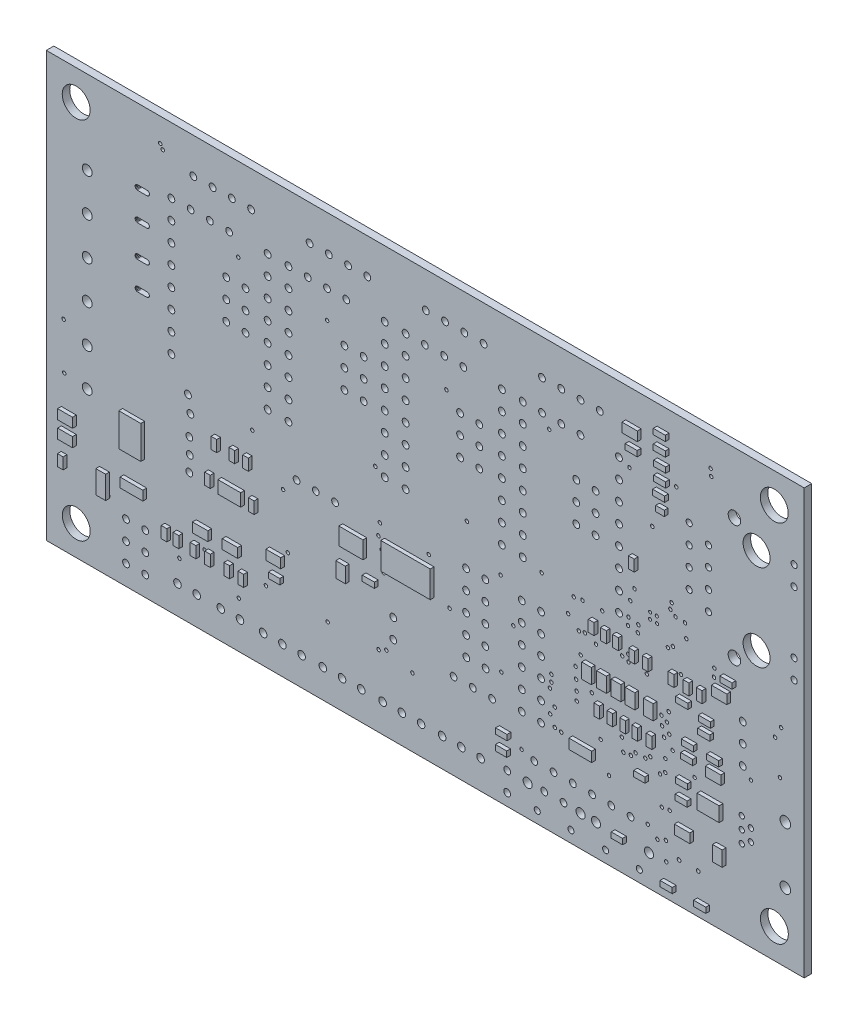
from build123d import *

# Parameters (mm, degrees)
SKETCH1_W           = 100
SKETCH1_H           = 56
SKETCH1_R           = 0.2286
SKETCH1_R_2         = 0.45
SKETCH1_R_3         = 0.2032
SKETCH1_R_4         = 0.4
SKETCH1_R_5         = 0.6
SKETCH1_R_6         = 1.778
SKETCH1_R_7         = 0.4064
SKETCH1_R_8         = 0.8255
SKETCH1_R_9         = 0.4445
SKETCH1_R_10        = 1.8415
SKETCH1_R_11        = 0.5
SKETCH1_R_12        = 0.65
SKETCH1_R_13        = 0.7
SKETCH1_R_14        = 0.35
SKETCH1_R_15        = 0.25
BOSS_EXTRUDE1_DEPTH = 0.991
SKETCH3_W           = 14.03
SKETCH3_H           = 14.03
BOSS_EXTRUDE2_DEPTH = 1.61
CHAMFER1_SIZE       = 0.61
CHAMFER2_SIZE       = 0.61
SKETCH4_W           = 1.304957509
SKETCH4_H           = 3.011808396
SKETCH4_W_2         = 0.747676452
SKETCH4_H_2         = 1.493492764
SKETCH4_W_3         = 1.967512926
SKETCH4_H_3         = 1.275000018
SKETCH4_H_4         = 1.275000015
SKETCH4_W_4         = 3.011798701
SKETCH4_H_5         = 1.246641716
SKETCH4_H_6         = 1.511746408
SKETCH4_W_5         = 0.747676453
SKETCH4_H_7         = 1.511746407
SKETCH4_W_6         = 0.765000025
SKETCH4_W_7         = 0.765000024
SKETCH4_H_8         = 1.493492763
SKETCH4_W_8         = 2.039999962
SKETCH4_H_9         = 1.246482293
SKETCH4_W_9         = 2.039999961
SKETCH4_W_10        = 1.967512925
SKETCH4_W_11        = 1.493492761
SKETCH4_H_10        = 0.74767645
SKETCH4_W_12        = 1.275000015
SKETCH4_H_11        = 2.015661876
SKETCH4_W_13        = 1.60649999
SKETCH4_H_12        = 0.726022008
SKETCH4_W_14        = 3.18
SKETCH4_H_13        = 2.28
SKETCH4_W_15        = 6.527994472
SKETCH4_H_14        = 3.518567085
SKETCH4_H_15        = 0.747676452
SKETCH4_W_16        = 1.511746405
SKETCH4_H_16        = 0.728187441
SKETCH4_W_17        = 1.587333678
SKETCH4_H_17        = 0.728187442
SKETCH4_W_18        = 1.587333679
SKETCH4_H_18        = 1.222102323
SKETCH4_H_19        = 1.222102324
SKETCH4_W_19        = 1.129246393
SKETCH4_H_20        = 0.726022005
SKETCH4_H_21        = 0.73035288
SKETCH4_W_20        = 1.275000018
SKETCH4_H_22        = 1.991323711
SKETCH4_W_21        = 2.91209749
SKETCH4_H_23        = 1.929775795
SKETCH4_W_22        = 1.275000016
SKETCH4_H_24        = 1.967512926
SKETCH4_H_25        = 1.967512925
SKETCH4_W_23        = 3.011808396
SKETCH4_H_26        = 1.304957507
SKETCH4_W_24        = 3.007851747
SKETCH4_H_27        = 1.656233035
SKETCH4_W_25        = 0.765000027
SKETCH4_H_28        = 1.568167369
SKETCH4_W_26        = 2.912100155
SKETCH4_H_29        = 4.346021334
BOSS_EXTRUDE3_DEPTH = 0.5


with BuildPart() as part:
    # Sketch1 → Boss-Extrude1 (new body)
    with BuildSketch(Plane.XY):
        with Locations((13.307133333, 19.688733333)):
            Rectangle(SKETCH1_W, SKETCH1_H)
        with Locations((16.517133333, 10.542066667)):
            Circle(SKETCH1_R, mode=Mode.SUBTRACT)
        with Locations((16.1038, 35.292066667)):
            Circle(SKETCH1_R, mode=Mode.SUBTRACT)
        with Locations((23.247133333, 17.708733333)):
            Circle(SKETCH1_R, mode=Mode.SUBTRACT)
        with Locations((28.654966667, 20.675)):
            Circle(SKETCH1_R, mode=Mode.SUBTRACT)
        with Locations((33.2873, 8.324)):
            Circle(SKETCH1_R, mode=Mode.SUBTRACT)
        with Locations((29.7584, 8.038833333)):
            Circle(SKETCH1_R, mode=Mode.SUBTRACT)
        with Locations((7.324866667, 15.717566667)):
            Circle(SKETCH1_R, mode=Mode.SUBTRACT)
        with Locations((0.357133333, 35.348733333)):
            Circle(SKETCH1_R, mode=Mode.SUBTRACT)
        with Locations((18.7985, 21.621333333)):
            Circle(SKETCH1_R, mode=Mode.SUBTRACT)
        with Locations((29.953666667, 9.716366667)):
            Circle(SKETCH1_R, mode=Mode.SUBTRACT)
        with Locations((29.957133333, 8.818733333)):
            Circle(SKETCH1_R, mode=Mode.SUBTRACT)
        with Locations((13.775033333, 15.313666667)):
            Circle(SKETCH1_R, mode=Mode.SUBTRACT)
        with Locations((-11.3662, 36.7154)):
            Circle(SKETCH1_R, mode=Mode.SUBTRACT)
        with Locations((-9.514866667, 17.868733333)):
            Circle(SKETCH1_R, mode=Mode.SUBTRACT)
        with Locations((31.240733333, 3.7565)):
            Circle(SKETCH1_R, mode=Mode.SUBTRACT)
        with Locations((23.347133333, 6.668733333)):
            Circle(SKETCH1_R, mode=Mode.SUBTRACT)
        with Locations((-4.822866667, 6.2254)):
            Circle(SKETCH1_R, mode=Mode.SUBTRACT)
        with Locations((-5.455866667, 13.126533333)):
            Circle(SKETCH1_R, mode=Mode.SUBTRACT)
        with Locations((44.280266667, 5.492133333)):
            Circle(SKETCH1_R, mode=Mode.SUBTRACT)
        with Locations((44.978, 6.005366667)):
            Circle(SKETCH1_R, mode=Mode.SUBTRACT)
        with Locations((44.4754, 12.311333333)):
            Circle(SKETCH1_R, mode=Mode.SUBTRACT)
        with Locations((43.267133333, 33.278733333)):
            Circle(SKETCH1_R, mode=Mode.SUBTRACT)
        with Locations((42.6598, -1.0665)):
            Circle(SKETCH1_R, mode=Mode.SUBTRACT)
        with Locations((34.367133333, 16.658733333)):
            Circle(SKETCH1_R, mode=Mode.SUBTRACT)
        with Locations((60.109233333, 12.993033333)):
            Circle(SKETCH1_R, mode=Mode.SUBTRACT)
        with Locations((34.054133333, 20.227433333)):
            Circle(SKETCH1_R, mode=Mode.SUBTRACT)
        with Locations((32.895666667, 20.0402)):
            Circle(SKETCH1_R, mode=Mode.SUBTRACT)
        with Locations((59.464766667, 17.276366667)):
            Circle(SKETCH1_R, mode=Mode.SUBTRACT)
        with Locations((35.836333333, 16.1019)):
            Circle(SKETCH1_R, mode=Mode.SUBTRACT)
        with Locations((45.058033333, -1.707333333)):
            Circle(SKETCH1_R, mode=Mode.SUBTRACT)
        with Locations((45.196033333, 11.876533333)):
            Circle(SKETCH1_R, mode=Mode.SUBTRACT)
        with Locations((45.497133333, 10.638733333)):
            Circle(SKETCH1_R, mode=Mode.SUBTRACT)
        with Locations((47.577133333, 24.406633333)):
            Circle(SKETCH1_R, mode=Mode.SUBTRACT)
        with Locations((45.942433333, 9.0166)):
            Circle(SKETCH1_R, mode=Mode.SUBTRACT)
        with Locations((7.1314, 14.127733333)):
            Circle(SKETCH1_R, mode=Mode.SUBTRACT)
        with Locations((8.1788, 1.5814)):
            Circle(SKETCH1_R, mode=Mode.SUBTRACT)
        with Locations((7.150466667, 1.132433333)):
            Circle(SKETCH1_R, mode=Mode.SUBTRACT)
        with Locations((7.560233333, 12.723533333)):
            Circle(SKETCH1_R, mode=Mode.SUBTRACT)
        with Locations((33.570733333, 16.4904)):
            Circle(SKETCH1_R, mode=Mode.SUBTRACT)
        with Locations((30.405466667, 3.868966667)):
            Circle(SKETCH1_R, mode=Mode.SUBTRACT)
        with Locations((33.817133333, 13.858733333)):
            Circle(SKETCH1_R, mode=Mode.SUBTRACT)
        with Locations((45.554133333, 1.960466667)):
            Circle(SKETCH1_R, mode=Mode.SUBTRACT)
        with Locations((44.522833333, 1.823566667)):
            Circle(SKETCH1_R, mode=Mode.SUBTRACT)
        with Locations((29.78, 5.116033333)):
            Circle(SKETCH1_R, mode=Mode.SUBTRACT)
        with Locations((35.280466667, 10.2754)):
            Circle(SKETCH1_R, mode=Mode.SUBTRACT)
        with Locations((33.137266667, 12.216166667)):
            Circle(SKETCH1_R, mode=Mode.SUBTRACT)
        with Locations((24.935866667, 12.76)):
            Circle(SKETCH1_R, mode=Mode.SUBTRACT)
        with Locations((44.9896, 7.609033333)):
            Circle(SKETCH1_R, mode=Mode.SUBTRACT)
        with Locations((36.447133333, 5.518733333)):
            Circle(SKETCH1_R, mode=Mode.SUBTRACT)
        with Locations((48.840466667, 7.3754)):
            Circle(SKETCH1_R, mode=Mode.SUBTRACT)
        with Locations((39.448433333, 5.549133333)):
            Circle(SKETCH1_R, mode=Mode.SUBTRACT)
        with Locations((40.437133333, 5.692066667)):
            Circle(SKETCH1_R, mode=Mode.SUBTRACT)
        with Locations((33.274433333, 9.458733333)):
            Circle(SKETCH1_R, mode=Mode.SUBTRACT)
        with Locations((33.2072, 10.780633333)):
            Circle(SKETCH1_R, mode=Mode.SUBTRACT)
        with Locations((-19.129533333, -1.5746)):
            Circle(SKETCH1_R, mode=Mode.SUBTRACT)
        with Locations((45.4266, 13.179366667)):
            Circle(SKETCH1_R, mode=Mode.SUBTRACT)
        with Locations((11.617133333, 0.7045)):
            Circle(SKETCH1_R, mode=Mode.SUBTRACT)
        with Locations((41.427133333, 21.1092)):
            Circle(SKETCH1_R, mode=Mode.SUBTRACT)
        with Locations((47.747133333, 22.678733333)):
            Circle(SKETCH1_R, mode=Mode.SUBTRACT)
        with Locations((40.917133333, 24.978733333)):
            Circle(SKETCH1_R, mode=Mode.SUBTRACT)
        with Locations((41.361033333, 20.165566667)):
            Circle(SKETCH1_R, mode=Mode.SUBTRACT)
        with Locations((46.427133333, 39.368733333)):
            Circle(SKETCH1_R, mode=Mode.SUBTRACT)
        with Locations((40.2556, 38.4838)):
            Circle(SKETCH1_R, mode=Mode.SUBTRACT)
        with Locations((40.357133333, 23.338733333)):
            Circle(SKETCH1_R, mode=Mode.SUBTRACT)
        with Locations((41.054133333, 6.2989)):
            Circle(SKETCH1_R, mode=Mode.SUBTRACT)
        with Locations((39.253133333, 7.182733333)):
            Circle(SKETCH1_R, mode=Mode.SUBTRACT)
        with Locations((42.338833333, 6.328733333)):
            Circle(SKETCH1_R, mode=Mode.SUBTRACT)
        with Locations((42.9945, 6.828033333)):
            Circle(SKETCH1_R, mode=Mode.SUBTRACT)
        with Locations((30.386433333, 6.186533333)):
            Circle(SKETCH1_R, mode=Mode.SUBTRACT)
        with Locations((-34.406866667, 18.111466667)):
            Circle(SKETCH1_R, mode=Mode.SUBTRACT)
        with Locations((-28.5043, 0.940866667)):
            Circle(SKETCH1_R, mode=Mode.SUBTRACT)
        with Locations((26.011566667, -0.8344)):
            Circle(SKETCH1_R, mode=Mode.SUBTRACT)
        with Locations((7.8107, 10.236633333)):
            Circle(SKETCH1_R, mode=Mode.SUBTRACT)
        with Locations((29.667133333, 37.558733333)):
            Circle(SKETCH1_R, mode=Mode.SUBTRACT)
        with Locations((45.657133333, 24.988733333)):
            Circle(SKETCH1_R, mode=Mode.SUBTRACT)
        with Locations((46.327133333, 24.488733333)):
            Circle(SKETCH1_R, mode=Mode.SUBTRACT)
        with Locations((45.807133333, 25.828733333)):
            Circle(SKETCH1_R, mode=Mode.SUBTRACT)
        with Locations((40.091166667, 17.0729)):
            Circle(SKETCH1_R, mode=Mode.SUBTRACT)
        with Locations((40.123066667, 16.205066667)):
            Circle(SKETCH1_R, mode=Mode.SUBTRACT)
        with Locations((40.120466667, 21.342066667)):
            Circle(SKETCH1_R, mode=Mode.SUBTRACT)
        with Locations((47.047133333, 18.238733333)):
            Circle(SKETCH1_R, mode=Mode.SUBTRACT)
        with Locations((51.4538, 21.1754)):
            Circle(SKETCH1_R, mode=Mode.SUBTRACT)
        with Locations((40.060466667, 20.342066667)):
            Circle(SKETCH1_R, mode=Mode.SUBTRACT)
        with Locations((36.657133333, 20.318733333)):
            Circle(SKETCH1_R, mode=Mode.SUBTRACT)
        with Locations((45.325533333, 20.4579)):
            Circle(SKETCH1_R, mode=Mode.SUBTRACT)
        with Locations((39.297133333, 16.488733333)):
            Circle(SKETCH1_R, mode=Mode.SUBTRACT)
        with Locations((45.987133333, 20.918733333)):
            Circle(SKETCH1_R, mode=Mode.SUBTRACT)
        with Locations((42.541533333, 16.037033333)):
            Circle(SKETCH1_R, mode=Mode.SUBTRACT)
        with Locations((-11.2929, -2.2113)):
            Circle(SKETCH1_R, mode=Mode.SUBTRACT)
        with Locations((32.157133333, 17.748733333)):
            Circle(SKETCH1_R, mode=Mode.SUBTRACT)
        with Locations((-15.7962, 1.048733333)):
            Circle(SKETCH1_R, mode=Mode.SUBTRACT)
        with Locations((45.107133333, -4.131266667)):
            Circle(SKETCH1_R, mode=Mode.SUBTRACT)
        with Locations((44.814766667, 9.958733333)):
            Circle(SKETCH1_R, mode=Mode.SUBTRACT)
        with Locations((0.4297, 0.934466667)):
            Circle(SKETCH1_R, mode=Mode.SUBTRACT)
        with Locations((43.940133333, -2.1493)):
            Circle(SKETCH1_R, mode=Mode.SUBTRACT)
        with Locations((51.4038, 20.1054)):
            Circle(SKETCH1_R, mode=Mode.SUBTRACT)
        with Locations((56.2838, 10.788733333)):
            Circle(SKETCH1_R, mode=Mode.SUBTRACT)
        with Locations((60.252366667, 18.778733333)):
            Circle(SKETCH1_R, mode=Mode.SUBTRACT)
        with Locations((44.5511, 11.129766667)):
            Circle(SKETCH1_R, mode=Mode.SUBTRACT)
        with Locations((-7.712866667, 1.008733333)):
            Circle(SKETCH1_R, mode=Mode.SUBTRACT)
        with Locations((6.717133333, 21.8554)):
            Circle(SKETCH1_R, mode=Mode.SUBTRACT)
        with Locations((37.554133333, 1.958466667)):
            Circle(SKETCH1_R, mode=Mode.SUBTRACT)
        with Locations((51.046, 42.863433333)):
            Circle(SKETCH1_R, mode=Mode.SUBTRACT)
        with Locations((50.954666667, 43.742866667)):
            Circle(SKETCH1_R, mode=Mode.SUBTRACT)
        with Locations((-21.327033333, 44.012166667)):
            Circle(SKETCH1_R, mode=Mode.SUBTRACT)
        with Locations((-21.664366667, 44.555966667)):
            Circle(SKETCH1_R, mode=Mode.SUBTRACT)
        with Locations((-34.329733333, 12.002933333)):
            Circle(SKETCH1_R, mode=Mode.SUBTRACT)
        with Locations((-9.669533333, 43.021366667)):
            Circle(SKETCH1_R_2, mode=Mode.SUBTRACT)
        with Locations((-12.209533333, 43.021366667)):
            Circle(SKETCH1_R_2, mode=Mode.SUBTRACT)
        with Locations((-14.749533333, 43.016733333)):
            Circle(SKETCH1_R_2, mode=Mode.SUBTRACT)
        with Locations((-17.289533333, 43.012066667)):
            Circle(SKETCH1_R_2, mode=Mode.SUBTRACT)
        with Locations((5.667133333, 43.031366667)):
            Circle(SKETCH1_R_2, mode=Mode.SUBTRACT)
        with Locations((3.127133333, 43.031366667)):
            Circle(SKETCH1_R_2, mode=Mode.SUBTRACT)
        with Locations((0.587133333, 43.026733333)):
            Circle(SKETCH1_R_2, mode=Mode.SUBTRACT)
        with Locations((-1.952866667, 43.022066667)):
            Circle(SKETCH1_R_2, mode=Mode.SUBTRACT)
        with Locations((21.0038, 43.021366667)):
            Circle(SKETCH1_R_2, mode=Mode.SUBTRACT)
        with Locations((18.4638, 43.021366667)):
            Circle(SKETCH1_R_2, mode=Mode.SUBTRACT)
        with Locations((15.9238, 43.016733333)):
            Circle(SKETCH1_R_2, mode=Mode.SUBTRACT)
        with Locations((13.3838, 43.012066667)):
            Circle(SKETCH1_R_2, mode=Mode.SUBTRACT)
        with Locations((36.3338, 43.001366667)):
            Circle(SKETCH1_R_2, mode=Mode.SUBTRACT)
        with Locations((33.7938, 43.001366667)):
            Circle(SKETCH1_R_2, mode=Mode.SUBTRACT)
        with Locations((31.2538, 42.996733333)):
            Circle(SKETCH1_R_2, mode=Mode.SUBTRACT)
        with Locations((28.7138, 42.992066667)):
            Circle(SKETCH1_R_2, mode=Mode.SUBTRACT)
        with Locations((42.977133333, 22.508733333)):
            Circle(SKETCH1_R_3, mode=Mode.SUBTRACT)
        with Locations((43.888866667, 22.474)):
            Circle(SKETCH1_R_3, mode=Mode.SUBTRACT)
        with Locations((43.854133333, 23.324933333)):
            Circle(SKETCH1_R_3, mode=Mode.SUBTRACT)
        with Locations((42.985833333, 23.324933333)):
            Circle(SKETCH1_R_3, mode=Mode.SUBTRACT)
        with Locations((32.531166667, -6.787266667)):
            Circle(SKETCH1_R_4, mode=Mode.SUBTRACT)
        with Locations((28.086166667, -6.787266667)):
            Circle(SKETCH1_R_4, mode=Mode.SUBTRACT)
        with Locations((33.801166667, -4.247266667)):
            Circle(SKETCH1_R_5, mode=Mode.SUBTRACT)
        with Locations((26.816166667, -4.247266667)):
            Circle(SKETCH1_R_5, mode=Mode.SUBTRACT)
        with Locations((57.024133333, 37.387733333)):
            Circle(SKETCH1_R_6, mode=Mode.SUBTRACT)
        with Locations((57.024133333, 25.957733333)):
            Circle(SKETCH1_R_6, mode=Mode.SUBTRACT)
        with Locations((61.977133333, 35.736733333)):
            Circle(SKETCH1_R_7, mode=Mode.SUBTRACT)
        with Locations((61.977133333, 38.276733333)):
            Circle(SKETCH1_R_7, mode=Mode.SUBTRACT)
        with Locations((48.134133333, 28.497733333)):
            Circle(SKETCH1_R_7, mode=Mode.SUBTRACT)
        with Locations((50.674133333, 27.227733333)):
            Circle(SKETCH1_R_7, mode=Mode.SUBTRACT)
        with Locations((54.103133333, 23.671733333)):
            Circle(SKETCH1_R_8, mode=Mode.SUBTRACT)
        with Locations((54.103133333, 39.673733333)):
            Circle(SKETCH1_R_8, mode=Mode.SUBTRACT)
        with Locations((48.134133333, 33.577733333)):
            Circle(SKETCH1_R_7, mode=Mode.SUBTRACT)
        with Locations((50.674133333, 29.767733333)):
            Circle(SKETCH1_R_7, mode=Mode.SUBTRACT)
        with Locations((50.674133333, 32.307733333)):
            Circle(SKETCH1_R_7, mode=Mode.SUBTRACT)
        with Locations((48.134133333, 31.037733333)):
            Circle(SKETCH1_R_7, mode=Mode.SUBTRACT)
        with Locations((50.674133333, 34.847733333)):
            Circle(SKETCH1_R_7, mode=Mode.SUBTRACT)
        with Locations((48.134133333, 36.117733333)):
            Circle(SKETCH1_R_7, mode=Mode.SUBTRACT)
        with Locations((61.977133333, 27.608733333)):
            Circle(SKETCH1_R_7, mode=Mode.SUBTRACT)
        with Locations((61.977133333, 25.068733333)):
            Circle(SKETCH1_R_7, mode=Mode.SUBTRACT)
        with Locations((9.088633333, 3.244966667)):
            Circle(SKETCH1_R_9, mode=Mode.SUBTRACT)
        with Locations((9.088633333, 5.784966667)):
            Circle(SKETCH1_R_9, mode=Mode.SUBTRACT)
        with Locations((21.269933333, 6.039733333)):
            Circle(SKETCH1_R_9, mode=Mode.SUBTRACT)
        with Locations((18.729933333, 6.039733333)):
            Circle(SKETCH1_R_9, mode=Mode.SUBTRACT)
        with Locations((41.5524, -6.778766667)):
            Circle(SKETCH1_R_4, mode=Mode.SUBTRACT)
        with Locations((37.1074, -6.778766667)):
            Circle(SKETCH1_R_4, mode=Mode.SUBTRACT)
        with Locations((42.8224, -4.238766667)):
            Circle(SKETCH1_R_5, mode=Mode.SUBTRACT)
        with Locations((35.8374, -4.238766667)):
            Circle(SKETCH1_R_5, mode=Mode.SUBTRACT)
        with Locations((59.3696, -4.380766667)):
            Circle(SKETCH1_R_10, mode=Mode.SUBTRACT)
        with Locations((59.360433333, 43.742233333)):
            Circle(SKETCH1_R_10, mode=Mode.SUBTRACT)
        with Locations((-32.7488, 43.734533333)):
            Circle(SKETCH1_R_10, mode=Mode.SUBTRACT)
        with Locations((-32.740366667, -4.374766667)):
            Circle(SKETCH1_R_10, mode=Mode.SUBTRACT)
        with Locations((-17.819533333, 12.9654)):
            Circle(SKETCH1_R_2, mode=Mode.SUBTRACT)
        with Locations((-17.818433333, 8.893166667)):
            Circle(SKETCH1_R_2, mode=Mode.SUBTRACT)
        with Locations((-17.762866667, 10.928733333)):
            Circle(SKETCH1_R_2, mode=Mode.SUBTRACT)
        with Locations((-17.682066667, 15.652966667)):
            Circle(SKETCH1_R_2, mode=Mode.SUBTRACT)
        with Locations((-18.002866667, 17.718733333)):
            Circle(SKETCH1_R_2, mode=Mode.SUBTRACT)
        with Locations((33.7912, 38.9854)):
            Circle(SKETCH1_R_9, mode=Mode.SUBTRACT)
        with Locations((31.2512, 38.9854)):
            Circle(SKETCH1_R_9, mode=Mode.SUBTRACT)
        with Locations((28.7112, 38.9854)):
            Circle(SKETCH1_R_9, mode=Mode.SUBTRACT)
        with Locations((26.1712, 21.2054)):
            Circle(SKETCH1_R_2, mode=Mode.SUBTRACT)
        with Locations((26.1712, 36.4454)):
            Circle(SKETCH1_R_2, mode=Mode.SUBTRACT)
        with Locations((38.8712, 36.4454)):
            Circle(SKETCH1_R_2, mode=Mode.SUBTRACT)
        with Locations((38.8712, 33.9054)):
            Circle(SKETCH1_R_2, mode=Mode.SUBTRACT)
        with Locations((38.8712, 31.3654)):
            Circle(SKETCH1_R_2, mode=Mode.SUBTRACT)
        with Locations((38.8712, 28.8254)):
            Circle(SKETCH1_R_2, mode=Mode.SUBTRACT)
        with Locations((38.8712, 26.2854)):
            Circle(SKETCH1_R_2, mode=Mode.SUBTRACT)
        with Locations((38.8712, 23.7454)):
            Circle(SKETCH1_R_2, mode=Mode.SUBTRACT)
        with Locations((26.1712, 23.7454)):
            Circle(SKETCH1_R_2, mode=Mode.SUBTRACT)
        with Locations((26.1712, 38.9854)):
            Circle(SKETCH1_R_2, mode=Mode.SUBTRACT)
        with Locations((38.8712, 21.2054)):
            Circle(SKETCH1_R_2, mode=Mode.SUBTRACT)
        with Locations((38.8712, 38.9854)):
            Circle(SKETCH1_R_2, mode=Mode.SUBTRACT)
        with Locations((26.1712, 26.2854)):
            Circle(SKETCH1_R_2, mode=Mode.SUBTRACT)
        with Locations((26.1712, 28.8254)):
            Circle(SKETCH1_R_2, mode=Mode.SUBTRACT)
        with Locations((26.1712, 33.9054)):
            Circle(SKETCH1_R_2, mode=Mode.SUBTRACT)
        with Locations((26.1712, 31.3654)):
            Circle(SKETCH1_R_2, mode=Mode.SUBTRACT)
        with Locations((18.337133333, 39.0254)):
            Circle(SKETCH1_R_9, mode=Mode.SUBTRACT)
        with Locations((15.797133333, 39.0254)):
            Circle(SKETCH1_R_9, mode=Mode.SUBTRACT)
        with Locations((13.257133333, 39.0254)):
            Circle(SKETCH1_R_9, mode=Mode.SUBTRACT)
        with Locations((10.717133333, 21.2454)):
            Circle(SKETCH1_R_2, mode=Mode.SUBTRACT)
        with Locations((10.717133333, 36.4854)):
            Circle(SKETCH1_R_2, mode=Mode.SUBTRACT)
        with Locations((23.417133333, 36.4854)):
            Circle(SKETCH1_R_2, mode=Mode.SUBTRACT)
        with Locations((23.417133333, 33.9454)):
            Circle(SKETCH1_R_2, mode=Mode.SUBTRACT)
        with Locations((23.417133333, 31.4054)):
            Circle(SKETCH1_R_2, mode=Mode.SUBTRACT)
        with Locations((23.417133333, 28.8654)):
            Circle(SKETCH1_R_2, mode=Mode.SUBTRACT)
        with Locations((23.417133333, 26.3254)):
            Circle(SKETCH1_R_2, mode=Mode.SUBTRACT)
        with Locations((23.417133333, 23.7854)):
            Circle(SKETCH1_R_2, mode=Mode.SUBTRACT)
        with Locations((10.717133333, 23.7854)):
            Circle(SKETCH1_R_2, mode=Mode.SUBTRACT)
        with Locations((10.717133333, 39.0254)):
            Circle(SKETCH1_R_2, mode=Mode.SUBTRACT)
        with Locations((23.417133333, 21.2454)):
            Circle(SKETCH1_R_2, mode=Mode.SUBTRACT)
        with Locations((23.417133333, 39.0254)):
            Circle(SKETCH1_R_2, mode=Mode.SUBTRACT)
        with Locations((10.717133333, 26.3254)):
            Circle(SKETCH1_R_2, mode=Mode.SUBTRACT)
        with Locations((10.717133333, 28.8654)):
            Circle(SKETCH1_R_2, mode=Mode.SUBTRACT)
        with Locations((10.717133333, 33.9454)):
            Circle(SKETCH1_R_2, mode=Mode.SUBTRACT)
        with Locations((10.717133333, 31.4054)):
            Circle(SKETCH1_R_2, mode=Mode.SUBTRACT)
        with Locations((2.8838, 39.0154)):
            Circle(SKETCH1_R_9, mode=Mode.SUBTRACT)
        with Locations((0.3438, 39.0154)):
            Circle(SKETCH1_R_9, mode=Mode.SUBTRACT)
        with Locations((-2.1962, 39.0154)):
            Circle(SKETCH1_R_9, mode=Mode.SUBTRACT)
        with Locations((-4.7362, 21.2354)):
            Circle(SKETCH1_R_2, mode=Mode.SUBTRACT)
        with Locations((-4.7362, 36.4754)):
            Circle(SKETCH1_R_2, mode=Mode.SUBTRACT)
        with Locations((7.9638, 36.4754)):
            Circle(SKETCH1_R_2, mode=Mode.SUBTRACT)
        with Locations((7.9638, 33.9354)):
            Circle(SKETCH1_R_2, mode=Mode.SUBTRACT)
        with Locations((7.9638, 31.3954)):
            Circle(SKETCH1_R_2, mode=Mode.SUBTRACT)
        with Locations((7.9638, 28.8554)):
            Circle(SKETCH1_R_2, mode=Mode.SUBTRACT)
        with Locations((7.9638, 26.3154)):
            Circle(SKETCH1_R_2, mode=Mode.SUBTRACT)
        with Locations((7.9638, 23.7754)):
            Circle(SKETCH1_R_2, mode=Mode.SUBTRACT)
        with Locations((-4.7362, 23.7754)):
            Circle(SKETCH1_R_2, mode=Mode.SUBTRACT)
        with Locations((-4.7362, 39.0154)):
            Circle(SKETCH1_R_2, mode=Mode.SUBTRACT)
        with Locations((7.9638, 21.2354)):
            Circle(SKETCH1_R_2, mode=Mode.SUBTRACT)
        with Locations((7.9638, 39.0154)):
            Circle(SKETCH1_R_2, mode=Mode.SUBTRACT)
        with Locations((-4.7362, 26.3154)):
            Circle(SKETCH1_R_2, mode=Mode.SUBTRACT)
        with Locations((-4.7362, 28.8554)):
            Circle(SKETCH1_R_2, mode=Mode.SUBTRACT)
        with Locations((-4.7362, 33.9354)):
            Circle(SKETCH1_R_2, mode=Mode.SUBTRACT)
        with Locations((-4.7362, 31.3954)):
            Circle(SKETCH1_R_2, mode=Mode.SUBTRACT)
        with Locations((-12.569533333, 39.0254)):
            Circle(SKETCH1_R_9, mode=Mode.SUBTRACT)
        with Locations((-15.109533333, 39.0254)):
            Circle(SKETCH1_R_9, mode=Mode.SUBTRACT)
        with Locations((-17.649533333, 39.0254)):
            Circle(SKETCH1_R_9, mode=Mode.SUBTRACT)
        with Locations((-20.189533333, 21.2454)):
            Circle(SKETCH1_R_2, mode=Mode.SUBTRACT)
        with Locations((-20.189533333, 36.4854)):
            Circle(SKETCH1_R_2, mode=Mode.SUBTRACT)
        with Locations((-7.489533333, 36.4854)):
            Circle(SKETCH1_R_2, mode=Mode.SUBTRACT)
        with Locations((-7.489533333, 33.9454)):
            Circle(SKETCH1_R_2, mode=Mode.SUBTRACT)
        with Locations((-7.489533333, 31.4054)):
            Circle(SKETCH1_R_2, mode=Mode.SUBTRACT)
        with Locations((-7.489533333, 28.8654)):
            Circle(SKETCH1_R_2, mode=Mode.SUBTRACT)
        with Locations((-7.489533333, 26.3254)):
            Circle(SKETCH1_R_2, mode=Mode.SUBTRACT)
        with Locations((-7.489533333, 23.7854)):
            Circle(SKETCH1_R_2, mode=Mode.SUBTRACT)
        with Locations((-20.189533333, 23.7854)):
            Circle(SKETCH1_R_2, mode=Mode.SUBTRACT)
        with Locations((-20.189533333, 39.0254)):
            Circle(SKETCH1_R_2, mode=Mode.SUBTRACT)
        with Locations((-7.489533333, 21.2454)):
            Circle(SKETCH1_R_2, mode=Mode.SUBTRACT)
        with Locations((-7.489533333, 39.0254)):
            Circle(SKETCH1_R_2, mode=Mode.SUBTRACT)
        with Locations((-20.189533333, 26.3254)):
            Circle(SKETCH1_R_2, mode=Mode.SUBTRACT)
        with Locations((-20.189533333, 28.8654)):
            Circle(SKETCH1_R_2, mode=Mode.SUBTRACT)
        with Locations((-20.189533333, 33.9454)):
            Circle(SKETCH1_R_2, mode=Mode.SUBTRACT)
        with Locations((-20.189533333, 31.4054)):
            Circle(SKETCH1_R_2, mode=Mode.SUBTRACT)
        with Locations((55.197133333, 16.9454)):
            Circle(SKETCH1_R_9, mode=Mode.SUBTRACT)
        with Locations((55.197133333, 14.4054)):
            Circle(SKETCH1_R_9, mode=Mode.SUBTRACT)
        with Locations((55.197133333, 11.8654)):
            Circle(SKETCH1_R_9, mode=Mode.SUBTRACT)
        with Locations((-13.6768, -4.579166667)):
            Circle(SKETCH1_R_11, mode=Mode.SUBTRACT)
        with Locations((-11.1368, -4.5745)):
            Circle(SKETCH1_R_11, mode=Mode.SUBTRACT)
        with Locations((-19.384666667, -4.579166667)):
            Circle(SKETCH1_R_11, mode=Mode.SUBTRACT)
        with Locations((-16.844666667, -4.5745)):
            Circle(SKETCH1_R_11, mode=Mode.SUBTRACT)
        with Locations((-3.672866667, 15.0986)):
            Circle(SKETCH1_R_9, mode=Mode.SUBTRACT)
        with Locations((-1.132866667, 15.0986)):
            Circle(SKETCH1_R_9, mode=Mode.SUBTRACT)
        with Locations((1.407133333, 15.0986)):
            Circle(SKETCH1_R_9, mode=Mode.SUBTRACT)
        with Locations((22.125833333, 3.001733333)):
            Circle(SKETCH1_R_9, mode=Mode.SUBTRACT)
        with Locations((19.585833333, 3.001733333)):
            Circle(SKETCH1_R_9, mode=Mode.SUBTRACT)
        with Locations((17.045833333, 3.001733333)):
            Circle(SKETCH1_R_9, mode=Mode.SUBTRACT)
        with Locations((15.531666667, -4.549433333)):
            Circle(SKETCH1_R_11, mode=Mode.SUBTRACT)
        with Locations((18.071666667, -4.5448)):
            Circle(SKETCH1_R_11, mode=Mode.SUBTRACT)
        with Locations((20.6117, -4.540133333)):
            Circle(SKETCH1_R_11, mode=Mode.SUBTRACT)
        with Locations((7.678066667, -4.549433333)):
            Circle(SKETCH1_R_11, mode=Mode.SUBTRACT)
        with Locations((10.218066667, -4.5448)):
            Circle(SKETCH1_R_11, mode=Mode.SUBTRACT)
        with Locations((12.7581, -4.540133333)):
            Circle(SKETCH1_R_11, mode=Mode.SUBTRACT)
        with Locations((-0.2119, -4.549433333)):
            Circle(SKETCH1_R_11, mode=Mode.SUBTRACT)
        with Locations((2.3281, -4.5448)):
            Circle(SKETCH1_R_11, mode=Mode.SUBTRACT)
        with Locations((4.868133333, -4.540133333)):
            Circle(SKETCH1_R_11, mode=Mode.SUBTRACT)
        with Locations((-8.0837, -4.585833333)):
            Circle(SKETCH1_R_11, mode=Mode.SUBTRACT)
        with Locations((-5.5437, -4.5812)):
            Circle(SKETCH1_R_11, mode=Mode.SUBTRACT)
        with Locations((-3.003666667, -4.576533333)):
            Circle(SKETCH1_R_11, mode=Mode.SUBTRACT)
        with Locations((-12.9462, 28.562066667)):
            Circle(SKETCH1_R_9, mode=Mode.SUBTRACT)
        with Locations((-12.9462, 31.102066667)):
            Circle(SKETCH1_R_9, mode=Mode.SUBTRACT)
        with Locations((-12.9462, 33.642066667)):
            Circle(SKETCH1_R_9, mode=Mode.SUBTRACT)
        with Locations((-10.4062, 28.562066667)):
            Circle(SKETCH1_R_9, mode=Mode.SUBTRACT)
        with Locations((-10.4062, 31.102066667)):
            Circle(SKETCH1_R_9, mode=Mode.SUBTRACT)
        with Locations((-10.4062, 33.642066667)):
            Circle(SKETCH1_R_9, mode=Mode.SUBTRACT)
        with Locations((2.640466667, 28.5454)):
            Circle(SKETCH1_R_9, mode=Mode.SUBTRACT)
        with Locations((2.640466667, 31.0854)):
            Circle(SKETCH1_R_9, mode=Mode.SUBTRACT)
        with Locations((2.640466667, 33.6254)):
            Circle(SKETCH1_R_9, mode=Mode.SUBTRACT)
        with Locations((5.180466667, 28.5454)):
            Circle(SKETCH1_R_9, mode=Mode.SUBTRACT)
        with Locations((5.180466667, 31.0854)):
            Circle(SKETCH1_R_9, mode=Mode.SUBTRACT)
        with Locations((5.180466667, 33.6254)):
            Circle(SKETCH1_R_9, mode=Mode.SUBTRACT)
        with Locations((17.899733333, 28.467933333)):
            Circle(SKETCH1_R_9, mode=Mode.SUBTRACT)
        with Locations((17.899733333, 31.007933333)):
            Circle(SKETCH1_R_9, mode=Mode.SUBTRACT)
        with Locations((17.899733333, 33.547933333)):
            Circle(SKETCH1_R_9, mode=Mode.SUBTRACT)
        with Locations((20.439733333, 28.467933333)):
            Circle(SKETCH1_R_9, mode=Mode.SUBTRACT)
        with Locations((20.439733333, 31.007933333)):
            Circle(SKETCH1_R_9, mode=Mode.SUBTRACT)
        with Locations((20.439733333, 33.547933333)):
            Circle(SKETCH1_R_9, mode=Mode.SUBTRACT)
        with Locations((33.238933333, 28.508733333)):
            Circle(SKETCH1_R_9, mode=Mode.SUBTRACT)
        with Locations((33.238933333, 31.048733333)):
            Circle(SKETCH1_R_9, mode=Mode.SUBTRACT)
        with Locations((33.238933333, 33.588733333)):
            Circle(SKETCH1_R_9, mode=Mode.SUBTRACT)
        with Locations((35.778933333, 28.508733333)):
            Circle(SKETCH1_R_9, mode=Mode.SUBTRACT)
        with Locations((35.778933333, 31.048733333)):
            Circle(SKETCH1_R_9, mode=Mode.SUBTRACT)
        with Locations((35.778933333, 33.588733333)):
            Circle(SKETCH1_R_9, mode=Mode.SUBTRACT)
        with Locations((24.1205, -6.733933333)):
            Circle(SKETCH1_R_9, mode=Mode.SUBTRACT)
        with Locations((24.1205, -4.193933333)):
            Circle(SKETCH1_R_9, mode=Mode.SUBTRACT)
        with Locations((27.696133333, -1.326266667)):
            Circle(SKETCH1_R_9, mode=Mode.SUBTRACT)
        with Locations((30.236133333, -1.326266667)):
            Circle(SKETCH1_R_9, mode=Mode.SUBTRACT)
        with Locations((32.776133333, -1.326266667)):
            Circle(SKETCH1_R_9, mode=Mode.SUBTRACT)
        with Locations((35.316133333, -1.326266667)):
            Circle(SKETCH1_R_9, mode=Mode.SUBTRACT)
        with Locations((37.856133333, -1.326266667)):
            Circle(SKETCH1_R_9, mode=Mode.SUBTRACT)
        with Locations((40.396133333, -1.326266667)):
            Circle(SKETCH1_R_9, mode=Mode.SUBTRACT)
        with Locations((-31.292866667, 11.688733333)):
            Circle(SKETCH1_R_12, mode=Mode.SUBTRACT)
        with Locations((-31.292866667, 16.688733333)):
            Circle(SKETCH1_R_12, mode=Mode.SUBTRACT)
        with Locations((-31.292866667, 21.688733333)):
            Circle(SKETCH1_R_12, mode=Mode.SUBTRACT)
        with Locations((-31.292866667, 26.688733333)):
            Circle(SKETCH1_R_12, mode=Mode.SUBTRACT)
        with Locations((-31.292866667, 31.688733333)):
            Circle(SKETCH1_R_12, mode=Mode.SUBTRACT)
        with Locations((-31.292866667, 36.688733333)):
            Circle(SKETCH1_R_12, mode=Mode.SUBTRACT)
        with Locations((60.8153, 8.2611)):
            Circle(SKETCH1_R_13, mode=Mode.SUBTRACT)
        with Locations((60.8153, 0.756366667)):
            Circle(SKETCH1_R_13, mode=Mode.SUBTRACT)
        with Locations((56.267133333, 5.308733333)):
            Circle(SKETCH1_R_14, mode=Mode.SUBTRACT)
        with Locations((56.267133333, 3.708733333)):
            Circle(SKETCH1_R_14, mode=Mode.SUBTRACT)
        with Locations((55.067133333, 6.108733333)):
            Circle(SKETCH1_R_14, mode=Mode.SUBTRACT)
        with Locations((55.067133333, 2.908733333)):
            Circle(SKETCH1_R_14, mode=Mode.SUBTRACT)
        with Locations((55.067133333, 4.508733333)):
            Circle(SKETCH1_R_14, mode=Mode.SUBTRACT)
        with Locations((28.585133333, 16.199733333)):
            Circle(SKETCH1_R_9, mode=Mode.SUBTRACT)
        with Locations((28.585133333, 13.659733333)):
            Circle(SKETCH1_R_9, mode=Mode.SUBTRACT)
        with Locations((28.585133333, 11.119733333)):
            Circle(SKETCH1_R_9, mode=Mode.SUBTRACT)
        with Locations((26.045133333, 16.199733333)):
            Circle(SKETCH1_R_9, mode=Mode.SUBTRACT)
        with Locations((26.045133333, 13.659733333)):
            Circle(SKETCH1_R_9, mode=Mode.SUBTRACT)
        with Locations((26.045133333, 11.119733333)):
            Circle(SKETCH1_R_9, mode=Mode.SUBTRACT)
        with Locations((-23.6384, -0.606133333)):
            Circle(SKETCH1_R_9, mode=Mode.SUBTRACT)
        with Locations((-23.6384, -3.146133333)):
            Circle(SKETCH1_R_9, mode=Mode.SUBTRACT)
        with Locations((-23.6384, -5.686133333)):
            Circle(SKETCH1_R_9, mode=Mode.SUBTRACT)
        with Locations((-26.1784, -0.606133333)):
            Circle(SKETCH1_R_9, mode=Mode.SUBTRACT)
        with Locations((-26.1784, -3.146133333)):
            Circle(SKETCH1_R_9, mode=Mode.SUBTRACT)
        with Locations((-26.1784, -5.686133333)):
            Circle(SKETCH1_R_9, mode=Mode.SUBTRACT)
        with Locations((28.585133333, 8.579733333)):
            Circle(SKETCH1_R_9, mode=Mode.SUBTRACT)
        with Locations((28.585133333, 6.039733333)):
            Circle(SKETCH1_R_9, mode=Mode.SUBTRACT)
        with Locations((28.585133333, 3.499733333)):
            Circle(SKETCH1_R_9, mode=Mode.SUBTRACT)
        with Locations((26.045133333, 8.579733333)):
            Circle(SKETCH1_R_9, mode=Mode.SUBTRACT)
        with Locations((26.045133333, 6.039733333)):
            Circle(SKETCH1_R_9, mode=Mode.SUBTRACT)
        with Locations((26.045133333, 3.499733333)):
            Circle(SKETCH1_R_9, mode=Mode.SUBTRACT)
        with Locations((18.694866667, 11.117866667)):
            Circle(SKETCH1_R_9, mode=Mode.SUBTRACT)
        with Locations((18.694866667, 13.657866667)):
            Circle(SKETCH1_R_9, mode=Mode.SUBTRACT)
        with Locations((18.694866667, 16.197866667)):
            Circle(SKETCH1_R_9, mode=Mode.SUBTRACT)
        with Locations((21.234866667, 11.117866667)):
            Circle(SKETCH1_R_9, mode=Mode.SUBTRACT)
        with Locations((21.234866667, 13.657866667)):
            Circle(SKETCH1_R_9, mode=Mode.SUBTRACT)
        with Locations((21.234866667, 16.197866667)):
            Circle(SKETCH1_R_9, mode=Mode.SUBTRACT)
        with Locations((21.234866667, 8.577866667)):
            Circle(SKETCH1_R_9, mode=Mode.SUBTRACT)
        with Locations((18.694866667, 8.577866667)):
            Circle(SKETCH1_R_9, mode=Mode.SUBTRACT)
        with Locations((31.5511, -4.145566667)):
            Circle(SKETCH1_R_9, mode=Mode.SUBTRACT)
        with Locations((29.0111, -4.145566667)):
            Circle(SKETCH1_R_9, mode=Mode.SUBTRACT)
        with Locations((46.796033334, -3.078433333)):
            Circle(SKETCH1_R_15, mode=Mode.SUBTRACT)
        with Locations((49.3193, -3.080266667)):
            Circle(SKETCH1_R_15, mode=Mode.SUBTRACT)
        Polygon((-23.29471012, 26.123533232), (-23.405866667, 26.103933333), (-24.655866667, 26.103933333), (-24.767023213, 26.123533232), (-24.86477264, 26.179968889), (-24.937324923, 26.266433333), (-24.975929186, 26.372497676), (-24.975929186, 26.485368991), (-24.937324923, 26.591433333), (-24.86477264, 26.677897777), (-24.767023213, 26.734333435), (-24.655866667, 26.753933333), (-23.29471012, 26.734333435), (-23.196960694, 26.677897777), (-23.12440841, 26.591433333), (-23.085804147, 26.485368991), (-23.085804147, 26.372497676), (-23.12440841, 26.266433333), (-23.196960694, 26.179968889), align=None, mode=Mode.SUBTRACT)
        Polygon((-23.29471012, 29.831933232), (-23.405866667, 29.812333333), (-24.655866667, 29.812333333), (-24.767023213, 29.831933232), (-24.86477264, 29.888368889), (-24.937324923, 29.974833333), (-24.975929186, 30.080897676), (-24.975929186, 30.193768991), (-24.937324923, 30.299833333), (-24.86477264, 30.386297777), (-24.767023213, 30.442733435), (-24.655866667, 30.462333333), (-23.29471012, 30.442733435), (-23.196960694, 30.386297777), (-23.12440841, 30.299833333), (-23.085804147, 30.193768991), (-23.085804147, 30.080897676), (-23.12440841, 29.974833333), (-23.196960694, 29.888368889), align=None, mode=Mode.SUBTRACT)
        Polygon((-23.29471012, 34.022933232), (-23.405866667, 34.003333333), (-24.655866667, 34.003333333), (-24.767023213, 34.022933232), (-24.86477264, 34.079368889), (-24.937324923, 34.165833333), (-24.975929186, 34.271897676), (-24.975929186, 34.384768991), (-24.937324923, 34.490833333), (-24.86477264, 34.577297777), (-24.767023213, 34.633733435), (-24.655866667, 34.653333333), (-23.29471012, 34.633733435), (-23.196960694, 34.577297777), (-23.12440841, 34.490833333), (-23.085804147, 34.384768991), (-23.085804147, 34.271897676), (-23.12440841, 34.165833333), (-23.196960694, 34.079368889), align=None, mode=Mode.SUBTRACT)
        Polygon((-23.29471012, 37.731333232), (-23.405866667, 37.711733333), (-24.655866667, 37.711733333), (-24.767023213, 37.731333232), (-24.86477264, 37.787768889), (-24.937324923, 37.874233333), (-24.975929186, 37.980297676), (-24.975929186, 38.093168991), (-24.937324923, 38.199233333), (-24.86477264, 38.285697777), (-24.767023213, 38.342133435), (-24.655866667, 38.361733333), (-23.29471012, 38.342133435), (-23.196960694, 38.285697777), (-23.12440841, 38.199233333), (-23.085804147, 38.093168991), (-23.085804147, 37.980297676), (-23.12440841, 37.874233333), (-23.196960694, 37.787768889), align=None, mode=Mode.SUBTRACT)
    extrude(amount=-BOSS_EXTRUDE1_DEPTH)

    # Sketch3 → Boss-Extrude2 (add)
    with BuildSketch(Plane(origin=(0, 0, -0.991), x_dir=(-1, 0, 0), z_dir=(0, 0, -1))):
        with Locations((-39.552133333, 10.953733333)):
            Rectangle(SKETCH3_W, SKETCH3_H)
    extrude(amount=BOSS_EXTRUDE2_DEPTH)

    # Chamfer1
    chamfer1_edges = [part.edges().sort_by_distance(p)[0] for p in [
        (32.537133333, 3.938733333, -1.796),
        (32.537133333, 17.968733333, -1.796),
        (46.567133333, 17.968733333, -1.796),
        (46.567133333, 3.938733333, -1.796),
    ]]
    chamfer(chamfer1_edges, length=CHAMFER1_SIZE)

    # Chamfer2
    chamfer2_edges = [part.edges().sort_by_distance(p)[0] for p in [
        (32.537133333, 10.953733333, -2.601),
        (39.552133333, 3.938733333, -2.601),
        (39.552133333, 17.968733333, -2.601),
        (46.567133333, 10.953733333, -2.601),
        (46.262133333, 4.243733333, -2.601),
        (46.262133333, 17.663733333, -2.601),
        (32.842133333, 17.663733333, -2.601),
        (32.842133333, 4.243733333, -2.601),
    ]]
    chamfer(chamfer2_edges, length=CHAMFER2_SIZE)

    # Sketch4 → Boss-Extrude3 (add)
    with BuildSketch(Plane.XY):
        with Locations((-29.013072917, 2.160349322)):
            Rectangle(SKETCH4_W, SKETCH4_H)
        with Locations((-34.343028453, 2.102133332)):
            Rectangle(SKETCH4_W_2, SKETCH4_H_2)
        with Locations((-33.719541666, 5.137699999)):
            Rectangle(SKETCH4_W_3, SKETCH4_H_3)
        with Locations((-33.719541666, 7.356366666)):
            Rectangle(SKETCH4_W_3, SKETCH4_H_4)
        with Locations((-24.959055525, 3.674748353)):
            Rectangle(SKETCH4_W_4, SKETCH4_H_5)
        with Locations((-20.660871545, 0.725260155)):
            Rectangle(SKETCH4_W_2, SKETCH4_H_6)
        with Locations((-19.088195119, 0.728593488)):
            Rectangle(SKETCH4_W_5, SKETCH4_H_6)
        with Locations((-16.834861785, 0.701926821)):
            Rectangle(SKETCH4_W_2, SKETCH4_H_7)
        with Locations((-14.930871545, 0.667126822)):
            Rectangle(SKETCH4_W_5, SKETCH4_H_6)
        with Locations((-12.384861785, 0.638593488)):
            Rectangle(SKETCH4_W_2, SKETCH4_H_6)
        with Locations((-10.531528453, 0.573793488)):
            Rectangle(SKETCH4_W_5, SKETCH4_H_6)
        with Locations((-14.934204878, 9.687860155)):
            Rectangle(SKETCH4_W_2, SKETCH4_H_7)
        with Locations((-14.084204879, 14.201643812)):
            Rectangle(SKETCH4_W_2, SKETCH4_H_7)
        with Locations((-11.710871546, 14.12220651)):
            Rectangle(SKETCH4_W_5, SKETCH4_H_7)
        with Locations((-9.911528452, 14.16700651)):
            Rectangle(SKETCH4_W_5, SKETCH4_H_6)
        with Locations((36.425138215, 8.99700651)):
            Rectangle(SKETCH4_W_5, SKETCH4_H_7)
        with Locations((38.156306111, 8.99541953)):
            Rectangle(SKETCH4_W_2, SKETCH4_H_6)
        with Locations((39.848471548, 9.018593487)):
            Rectangle(SKETCH4_W_2, SKETCH4_H_6)
        with Locations((41.449639443, 8.990339843)):
            Rectangle(SKETCH4_W_2, SKETCH4_H_7)
        with Locations((35.694433334, 18.182933332)):
            Rectangle(SKETCH4_W_6, SKETCH4_H_2)
        with Locations((37.309298771, 18.055796385)):
            Rectangle(SKETCH4_W_6, SKETCH4_H_2)
        with Locations((38.909298771, 18.065796386)):
            Rectangle(SKETCH4_W_7, SKETCH4_H_8)
        with Locations((41.057133335, 17.608333333)):
            Rectangle(SKETCH4_W_6, SKETCH4_H_2)
        with Locations((42.837133336, 17.618333333)):
            Rectangle(SKETCH4_W_7, SKETCH4_H_2)
        with Locations((40.999298772, 28.098663054)):
            Rectangle(SKETCH4_W_6, SKETCH4_H_8)
        with Locations((46.239298772, 17.52007969)):
            Rectangle(SKETCH4_W_6, SKETCH4_H_8)
        with Locations((48.214332104, 17.550079688)):
            Rectangle(SKETCH4_W_7, SKETCH4_H_2)
        with Locations((49.947133335, 17.528333333)):
            Rectangle(SKETCH4_W_6, SKETCH4_H_2)
        with Locations((-15.896158617, 3.320013748)):
            Rectangle(SKETCH4_W_8, SKETCH4_H_9)
        with Locations((-11.959491952, 3.375553022)):
            Rectangle(SKETCH4_W_9, SKETCH4_H_9)
        with Locations((-6.242858332, 5.038733333)):
            Rectangle(SKETCH4_W_10, SKETCH4_H_4)
        with Locations((-6.132133334, 2.867395119)):
            Rectangle(SKETCH4_W_11, SKETCH4_H_10)
        with Locations((2.637133335, 7.967535425)):
            Rectangle(SKETCH4_W_12, SKETCH4_H_11)
        with Locations((6.294700001, 8.706733332)):
            Rectangle(SKETCH4_W_13, SKETCH4_H_12)
        with Locations((3.997133335, 11.998733333)):
            Rectangle(SKETCH4_W_14, SKETCH4_H_13)
        with Locations((11.201186031, 12.495676588)):
            Rectangle(SKETCH4_W_15, SKETCH4_H_14)
        with Locations((23.811966667, -1.869471548)):
            Rectangle(SKETCH4_W_11, SKETCH4_H_15)
        with Locations((23.840906512, 0.049149384)):
            Rectangle(SKETCH4_W_16, SKETCH4_H_16)
        with Locations((44.683983512, 44.677650614)):
            Rectangle(SKETCH4_W_17, SKETCH4_H_17)
        with Locations((44.683983512, 42.889816049)):
            Rectangle(SKETCH4_W_17, SKETCH4_H_17)
        with Locations((44.733653791, 41.077650613)):
            Rectangle(SKETCH4_W_17, SKETCH4_H_16)
        with Locations((44.723653793, 39.367650615)):
            Rectangle(SKETCH4_W_17, SKETCH4_H_16)
        with Locations((44.593983511, 37.67981605)):
            Rectangle(SKETCH4_W_18, SKETCH4_H_17)
        with Locations((40.980283157, 41.080983946)):
            Rectangle(SKETCH4_W_17, SKETCH4_H_16)
        with Locations((47.573200149, 4.329816049)):
            Rectangle(SKETCH4_W_17, SKETCH4_H_16)
        with Locations((47.601720458, 6.306683947)):
            Rectangle(SKETCH4_W_18, SKETCH4_H_16)
        with Locations((48.306183512, 9.449816051)):
            Rectangle(SKETCH4_W_18, SKETCH4_H_16)
        with Locations((48.379516845, 11.043149385)):
            Rectangle(SKETCH4_W_18, SKETCH4_H_16)
        with Locations((50.553200148, 13.359816049)):
            Rectangle(SKETCH4_W_17, SKETCH4_H_17)
        with Locations((50.633200148, 14.88981605)):
            Rectangle(SKETCH4_W_17, SKETCH4_H_16)
        with Locations((51.726533481, 11.00981605)):
            Rectangle(SKETCH4_W_18, SKETCH4_H_17)
        with Locations((51.783941384, 9.278099491)):
            Rectangle(SKETCH4_W_9, SKETCH4_H_18)
        with Locations((47.690466669, 0.601432823)):
            Rectangle(SKETCH4_W_9, SKETCH4_H_19)
        with Locations((52.580500285, 18.921432823)):
            Rectangle(SKETCH4_W_9, SKETCH4_H_18)
        with Locations((40.773766385, 43.07603384)):
            Rectangle(SKETCH4_W_9, SKETCH4_H_19)
        with Locations((44.778856519, 36.039816051)):
            Rectangle(SKETCH4_W_19, SKETCH4_H_16)
        with Locations((53.473566667, 20.775399998)):
            Rectangle(SKETCH4_W_13, SKETCH4_H_20)
        with Locations((43.328471548, 8.988593489)):
            Rectangle(SKETCH4_W_2, SKETCH4_H_7)
        with Locations((39.095233335, -4.209533335)):
            Rectangle(SKETCH4_W_11, SKETCH4_H_21)
        with Locations((42.047866666, 4.288733334)):
            Rectangle(SKETCH4_W_11, SKETCH4_H_21)
        with Locations((45.5891, -6.534600002)):
            Rectangle(SKETCH4_W_13, SKETCH4_H_20)
        with Locations((50.015166667, -6.574600001)):
            Rectangle(SKETCH4_W_13, SKETCH4_H_20)
        with Locations((52.347133334, 0.40869199)):
            Rectangle(SKETCH4_W_20, SKETCH4_H_22)
        with Locations((51.123052282, 5.286556152)):
            Rectangle(SKETCH4_W_21, SKETCH4_H_23)
        with Locations((35.078866668, 12.636091666)):
            Rectangle(SKETCH4_W_22, SKETCH4_H_24)
        with Locations((37.060466667, 12.636091666)):
            Rectangle(SKETCH4_W_22, SKETCH4_H_24)
        with Locations((38.977800001, 12.632391666)):
            Rectangle(SKETCH4_W_12, SKETCH4_H_25)
        with Locations((40.823100001, 12.616091665)):
            Rectangle(SKETCH4_W_12, SKETCH4_H_24)
        with Locations((43.231800002, 12.577841665)):
            Rectangle(SKETCH4_W_12, SKETCH4_H_25)
        with Locations((47.643566668, 15.542066666)):
            Rectangle(SKETCH4_W_13, SKETCH4_H_20)
        with Locations((34.253282656, 3.427872917)):
            Rectangle(SKETCH4_W_23, SKETCH4_H_26)
        with Locations((-12.055695191, 9.627877033)):
            Rectangle(SKETCH4_W_24, SKETCH4_H_27)
        with Locations((-9.152866665, 9.629366666)):
            Rectangle(SKETCH4_W_25, SKETCH4_H_28)
        with Locations((-25.176133333, 9.616777378)):
            Rectangle(SKETCH4_W_26, SKETCH4_H_29)
    extrude(amount=BOSS_EXTRUDE3_DEPTH)


solid = part.part
